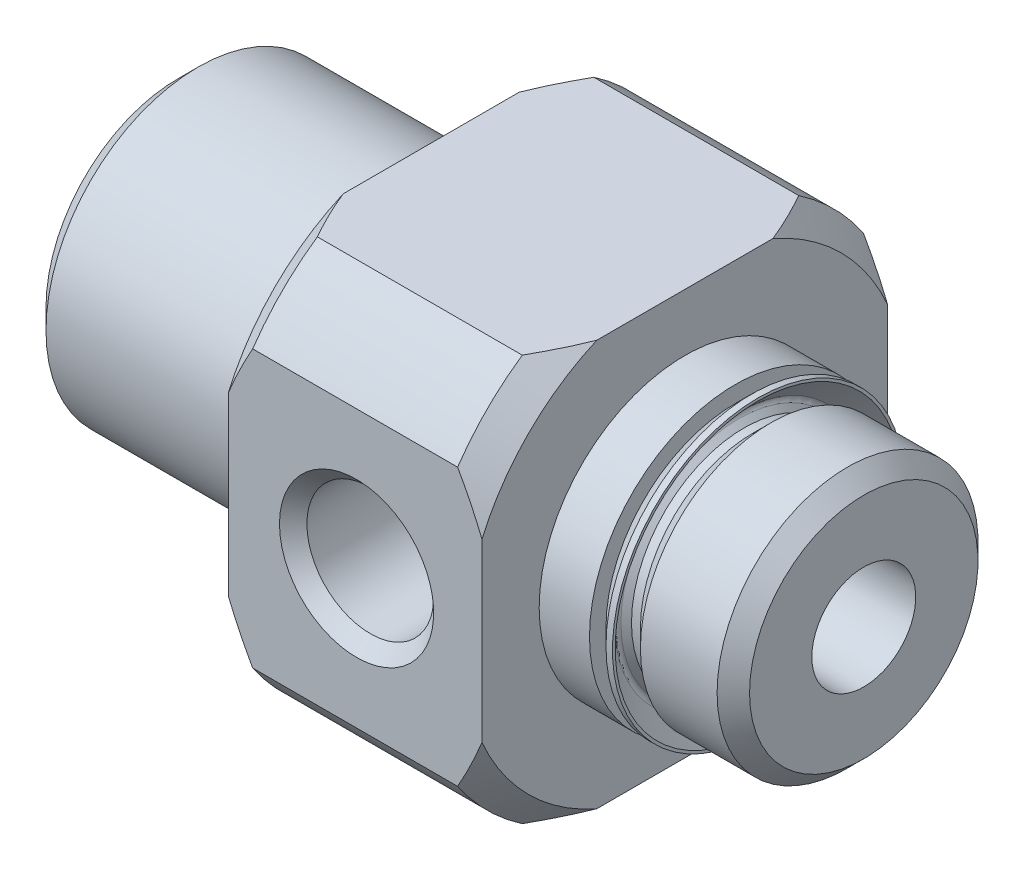
from build123d import *

# Parameters (mm, degrees)
SKETCH3_W          = 1.5748
SKETCH3_H          = 4.5593
SKETCH5_W          = 25.4
SKETCH5_H          = 25.4
SKETCH5_W_2        = 12.7
SKETCH5_H_2        = 12.7
CUT_EXTRUDE1_DEPTH = 21.463


with BuildPart() as part:
    # Sketch1 → Revolve1 (revolve)
    with BuildSketch(Plane.XY):
        Polygon((0, 0), (0, 4.13258), (0.62992, 4.7625), (7.9248, 4.7625), (7.9248, 0), align=None)
    revolve(axis=Axis((7.9248, 0, 0), (-1, 0, 0)))

    # Sketch2 → Revolve2 (revolve)
    with BuildSketch(Plane.XY):
        Polygon((7.9248, 0), (7.9248, 6.9215), (8.6868, 7.6835), (15.1003, 7.6835), (15.8623, 6.9215), (15.8623, 3.52425), (17.9959, 3.52425), (18.5547, 4.08305), (20.955, 4.08305), (21.463, 3.57505), (21.463, 0), align=None)
    revolve(axis=Axis((21.463, 0, 0), (-1, 0, 0)))

    # Sketch3 → Revolve3 (revolve)
    with BuildSketch(Plane.XY):
        with Locations((16.6497, 2.27965)):
            Rectangle(SKETCH3_W, SKETCH3_H)
    revolve(axis=Axis((17.4371, 0, 0), (-1, 0, 0)))

    # Sketch4 → Cut-Revolve1 (revolve, cut)
    with BuildSketch(Plane.XY):
        Polygon((0, 0), (0, 2.0066), (0.381, 1.6256), (21.463, 1.6256), (21.463, 0), align=None)
    revolve(axis=Axis((21.463, 0, 0), (-1, 0, 0)), mode=Mode.SUBTRACT)

    # Sketch5 → Cut-Extrude1 (cut)
    with BuildSketch(Plane(origin=(0, 0, 0), x_dir=(0, 0, -1), z_dir=(1, 0, 0))):
        Rectangle(SKETCH5_W, SKETCH5_H)
        Rectangle(SKETCH5_W_2, SKETCH5_H_2, mode=Mode.SUBTRACT)
    extrude(amount=CUT_EXTRUDE1_DEPTH, mode=Mode.SUBTRACT)

    # Sketch6 → Cut-Revolve2 (revolve, cut)
    with BuildSketch(Plane(origin=(0, 0, 0), x_dir=(1, 0, 0), z_dir=(0, 1, 0))):
        Polygon((11.938, 0), (13.92174, 0), (13.92174, -5.92074), (14.351, -6.35), (11.938, -6.35), align=None)
    revolve(axis=Axis((11.938, 0, 6.35), (0, 0, -1)), mode=Mode.SUBTRACT)

    # Sketch7 → Revolve4 (revolve)
    with BuildSketch(Plane.XY):
        with BuildLine():
            Line((17.4371, 4.043080735), (17.4371, 3.27025))
            Line((17.4371, 3.27025), (17.9959, 3.27025))
            Line((17.9959, 3.27025), (17.9959, 3.52425))
            Line((17.9959, 3.52425), (17.7165, 3.52425))
            Line((17.7165, 3.52425), (17.550871292, 3.689878708))
            ThreePointArc((17.550871292, 3.689878708), (17.513673853, 3.779681269), (17.550871292, 3.869483831))
            Line((17.550871292, 3.869483831), (18.156519265, 4.475131804))
            Line((18.156519265, 4.475131804), (18.156519265, 4.5593))
            Line((18.156519265, 4.5593), (17.953319265, 4.5593))
            Line((17.953319265, 4.5593), (17.4371, 4.043080735))
        make_face()
    revolve(axis=Axis((17.9959, 0, 0), (-1, 0, 0)))


solid = part.part
